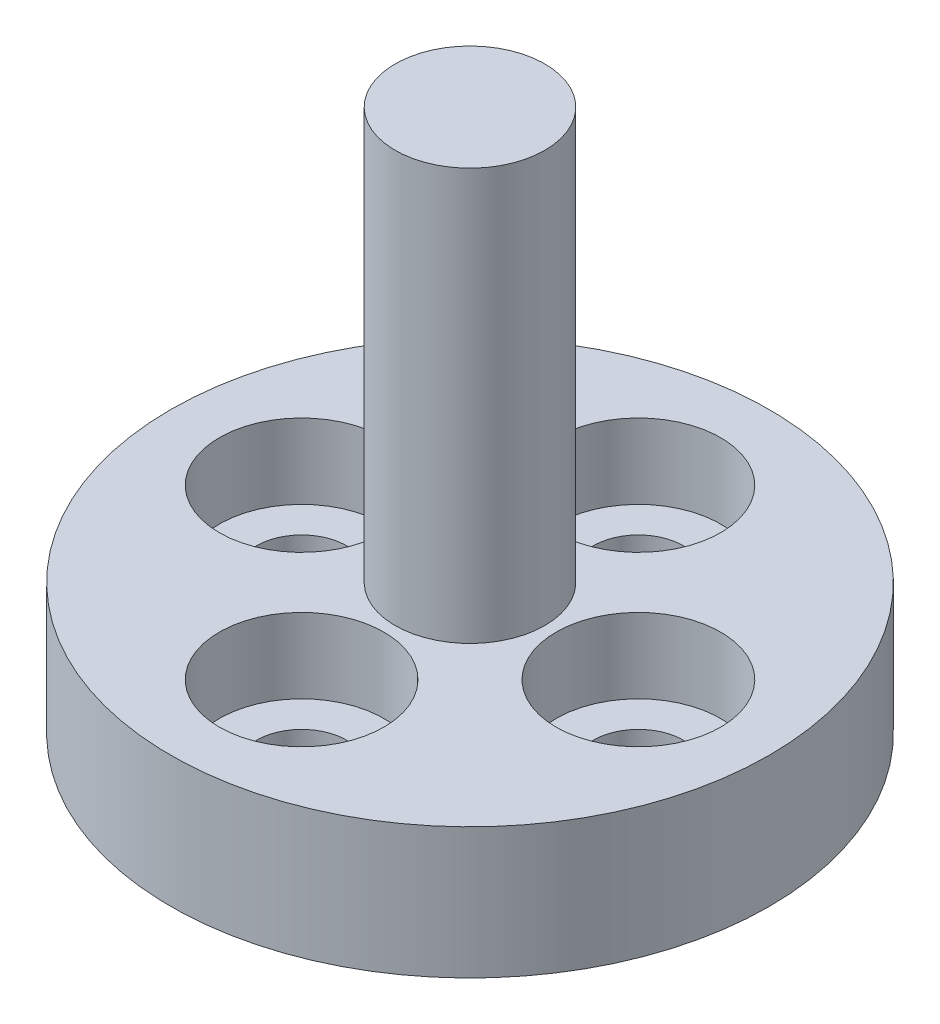
from build123d import *

# Parameters (mm, degrees)
CBORE_FOR_M2_SHCS1_D           = 2.4
CBORE_FOR_M2_SHCS1_CBORE_D     = 4.4
CBORE_FOR_M2_SHCS1_CBORE_DEPTH = 2


with BuildPart() as part:
    # Sketch3 → Revolve1 (revolve)
    with BuildSketch(Plane.XY):
        Polygon((0, 0), (0, 14.5), (2, 14.5), (2, 3.5), (8, 3.5), (8, 0), align=None)
    revolve(axis=Axis((0, 0, 0), (0, 1, 0)))

    # CBORE for M2 SHCS1 (through all)
    with Locations(Plane(origin=(0, 3.5, 0), x_dir=(1, 0, 0), z_dir=(0, 1, 0))):
        with Locations((-4.5, 0), (0, 4.5), (4.5, 0), (0, -4.5)):
            CounterBoreHole(CBORE_FOR_M2_SHCS1_D / 2, CBORE_FOR_M2_SHCS1_CBORE_D / 2, CBORE_FOR_M2_SHCS1_CBORE_DEPTH)


solid = part.part
